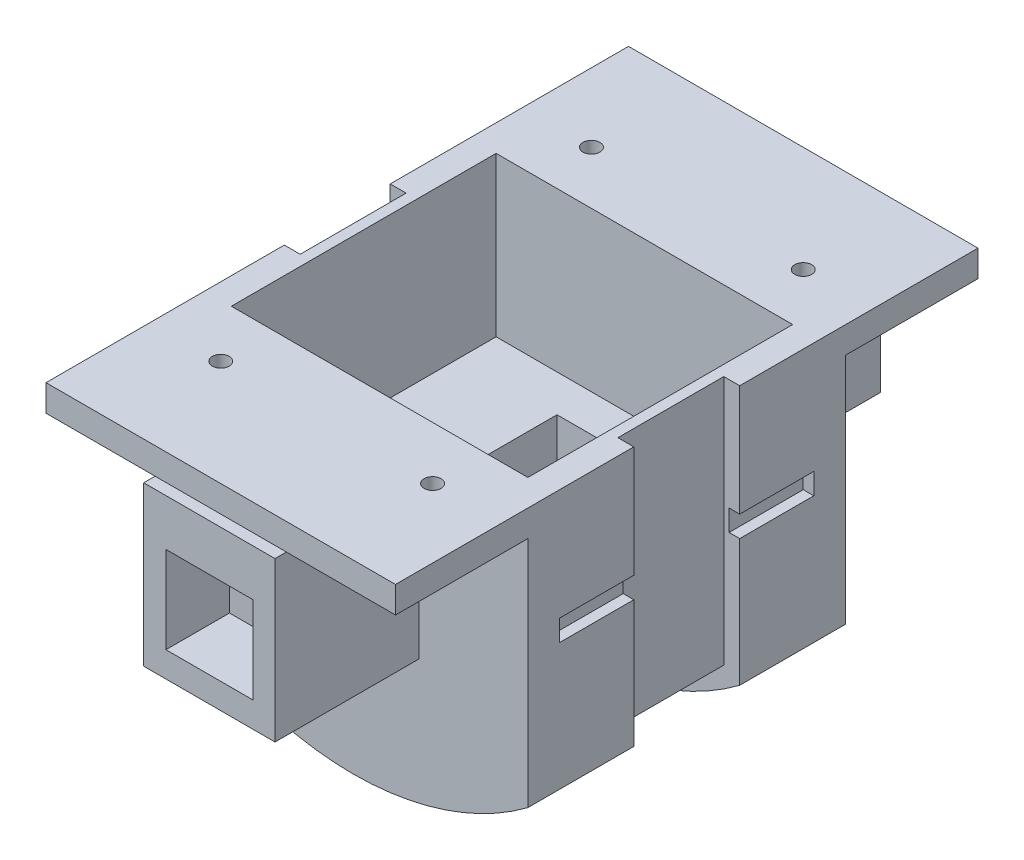
from build123d import *

# Parameters (mm, degrees)
BOSS_EXTRUDE1_DEPTH      = 30
BOSS_EXTRUDE1_DEPTH_BACK = 30
CUT_EXTRUDE1_DEPTH       = 18
CUT_EXTRUDE1_DEPTH_BACK  = 18
SKETCH2_W                = 19
SKETCH2_H                = 52
SKETCH3_W                = 21.854352608
SKETCH3_H                = 45
CUT_EXTRUDE2_DEPTH       = 99.234413522
SKETCH4_R                = 1.6
CUT_EXTRUDE3_DEPTH       = 84.366660003
SKETCH6_W                = 48
SKETCH6_H                = 4
CUT_EXTRUDE5_DEPTH       = 2
SKETCH9_W                = 22
SKETCH9_H                = 60
CUT_EXTRUDE7_DEPTH       = 84.366660003
SKETCH10_W               = 66
SKETCH10_H               = 110
SKETCH10_W_2             = 19
SKETCH10_H_2             = 36
BOSS_EXTRUDE2_DEPTH      = 5
SKETCH11_R               = 1.6
CUT_EXTRUDE8_DEPTH       = 88.82938005
SKETCH13_W               = 24.8
SKETCH13_H               = 30
BOSS_EXTRUDE3_DEPTH      = 27.15
SKETCH14_W               = 16.4
SKETCH14_H               = 16.4
CUT_EXTRUDE9_DEPTH       = 12
SKETCH15_W               = 56
SKETCH15_H               = 50
CUT_EXTRUDE10_DEPTH      = 30
SKETCH16_W               = 19
SKETCH16_H               = 20
CUT_EXTRUDE11_DEPTH      = 45
CUT_EXTRUDE19_DEPTH      = 10
CUT_EXTRUDE19_DEPTH_BACK = 10


with BuildPart() as part:
    # Sketch1 → Boss-Extrude1 (new, two sides: drawn at the far end of the back side and taken through both)
    with BuildSketch(Plane.XY.offset(-BOSS_EXTRUDE1_DEPTH_BACK)):
        with BuildLine():
            Line((55, 0), (0, 0))
            Line((0, 0), (-55, 0))
            ThreePointArc((-55, 0), (0, -55), (55, 0))
        make_face()
    extrude(amount=BOSS_EXTRUDE1_DEPTH + BOSS_EXTRUDE1_DEPTH_BACK)

    # Sketch2 → Cut-Extrude1 (cut, two sides: drawn at the far end of the back side and taken through both)
    with BuildSketch(Plane.XY.offset(-CUT_EXTRUDE1_DEPTH_BACK)):
        with Locations((0, -26)):
            Rectangle(SKETCH2_W, SKETCH2_H)
    extrude(amount=CUT_EXTRUDE1_DEPTH + CUT_EXTRUDE1_DEPTH_BACK, mode=Mode.SUBTRACT)

    # Sketch3 → Cut-Extrude2 (cut, through all)
    with BuildSketch(Plane.XY.offset(30)):
        with Locations((-43.927176304, -26.5)):
            Rectangle(SKETCH3_W, SKETCH3_H)
        with Locations((43.927176304, -26.5)):
            Rectangle(SKETCH3_W, SKETCH3_H)
    extrude(amount=-CUT_EXTRUDE2_DEPTH, mode=Mode.SUBTRACT)

    # Sketch4 → Cut-Extrude3 (cut, through all)
    with BuildSketch(Plane(origin=(0, 0, 0), x_dir=(1, 0, 0), z_dir=(0, 1, 0))):
        with Locations((45, 20)):
            Circle(SKETCH4_R)
        with Locations((45, -20)):
            Circle(SKETCH4_R)
        with Locations((-45, -20)):
            Circle(SKETCH4_R)
        with Locations((-45, 20)):
            Circle(SKETCH4_R)
    extrude(amount=-CUT_EXTRUDE3_DEPTH, mode=Mode.SUBTRACT)

    # Sketch6 → Cut-Extrude5 (cut)
    with BuildSketch(Plane(origin=(33, 0, 0), x_dir=(0, 0, -1), z_dir=(1, 0, 0))):
        with Locations((0, -18)):
            Rectangle(SKETCH6_W, SKETCH6_H)
    extrude(amount=-CUT_EXTRUDE5_DEPTH, mode=Mode.SUBTRACT)

    # Sketch9 → Cut-Extrude7 (cut, through all)
    with BuildSketch(Plane(origin=(0, 0, 0), x_dir=(1, 0, 0), z_dir=(0, 1, 0))):
        with Locations((-44, 0)):
            Rectangle(SKETCH9_W, SKETCH9_H)
        with Locations((44, 0)):
            Rectangle(SKETCH9_W, SKETCH9_H)
    extrude(amount=-CUT_EXTRUDE7_DEPTH, mode=Mode.SUBTRACT)

    # Sketch10 → Boss-Extrude2 (add)
    with BuildSketch(Plane(origin=(0, 0, 0), x_dir=(1, 0, 0), z_dir=(0, 1, 0))):
        Rectangle(SKETCH10_W, SKETCH10_H)
        Rectangle(SKETCH10_W_2, SKETCH10_H_2, mode=Mode.SUBTRACT)
    extrude(amount=BOSS_EXTRUDE2_DEPTH)

    # Sketch11 → Cut-Extrude8 (cut, through all)
    with BuildSketch(Plane(origin=(0, 5, 0), x_dir=(1, 0, 0), z_dir=(0, 1, 0))):
        with Locations((-20, 35)):
            Circle(SKETCH11_R)
        with Locations((20, 35)):
            Circle(SKETCH11_R)
        with Locations((-20, -35)):
            Circle(SKETCH11_R)
        with Locations((20, -35)):
            Circle(SKETCH11_R)
    extrude(amount=-CUT_EXTRUDE8_DEPTH, mode=Mode.SUBTRACT)

    # Sketch13 → Boss-Extrude3 (add)
    with BuildSketch(Plane(origin=(0, 0, -30), x_dir=(-1, 0, 0), z_dir=(0, 0, -1))):
        with Locations((0, -15)):
            Rectangle(SKETCH13_W, SKETCH13_H)
    boss_extrude3 = extrude(amount=BOSS_EXTRUDE3_DEPTH)

    # Sketch14 → Cut-Extrude9 (cut)
    with BuildSketch(Plane(origin=(0, 0, -57.15), x_dir=(-1, 0, 0), z_dir=(0, 0, -1))):
        with Locations((0, -17)):
            Rectangle(SKETCH14_W, SKETCH14_H)
    cut_extrude9 = extrude(amount=-CUT_EXTRUDE9_DEPTH, mode=Mode.SUBTRACT)

    # Mirror2: Boss-Extrude3 across plane
    add(boss_extrude3.mirror(Plane(origin=(0, 0, 0), x_dir=(1, 0, 0), z_dir=(0, 0, -1))))

    # Mirror3: Cut-Extrude9 across plane
    add(cut_extrude9.mirror(Plane(origin=(0, 0, 0), x_dir=(1, 0, 0), z_dir=(0, 0, -1))), mode=Mode.SUBTRACT)

    # Sketch15 → Cut-Extrude10 (cut)
    with BuildSketch(Plane(origin=(0, 5, 0), x_dir=(1, 0, 0), z_dir=(0, 1, 0))):
        Rectangle(SKETCH15_W, SKETCH15_H)
    extrude(amount=-CUT_EXTRUDE10_DEPTH, mode=Mode.SUBTRACT)

    # Sketch16 → Cut-Extrude11 (cut)
    with BuildSketch(Plane(origin=(0, -52, 0), x_dir=(1, 0, 0), z_dir=(0, 1, 0))):
        Rectangle(SKETCH16_W, SKETCH16_H)
    extrude(amount=-CUT_EXTRUDE11_DEPTH, mode=Mode.SUBTRACT)

    # Sketch18 → Cut-Extrude19 (cut, two sides: drawn at the far end of the back side and taken through both)
    with BuildSketch(Plane(origin=(0, 0, 0), x_dir=(-1, 0, 0), z_dir=(0, 0, -1)).offset(-CUT_EXTRUDE19_DEPTH_BACK)):
        Polygon((9.5, -49.173332923), (30, -42.194609519), (30, -41.173332923), (30, 5), (33, 5), (33, -41.173332923), (33, -54.173332923), (29.677482196, -54.173332923), (9.5, -54.173332923), align=None)
        Polygon((-30, -41.173332923), (-30, -42.194609519), (-9.5, -49.173332923), (-9.5, -54.173332923), (-29.677482196, -54.173332923), (-33, -54.173332923), (-33, -41.173332923), (-33, 5), (-30, 5), align=None)
    extrude(amount=CUT_EXTRUDE19_DEPTH + CUT_EXTRUDE19_DEPTH_BACK, mode=Mode.SUBTRACT)


solid = part.part
